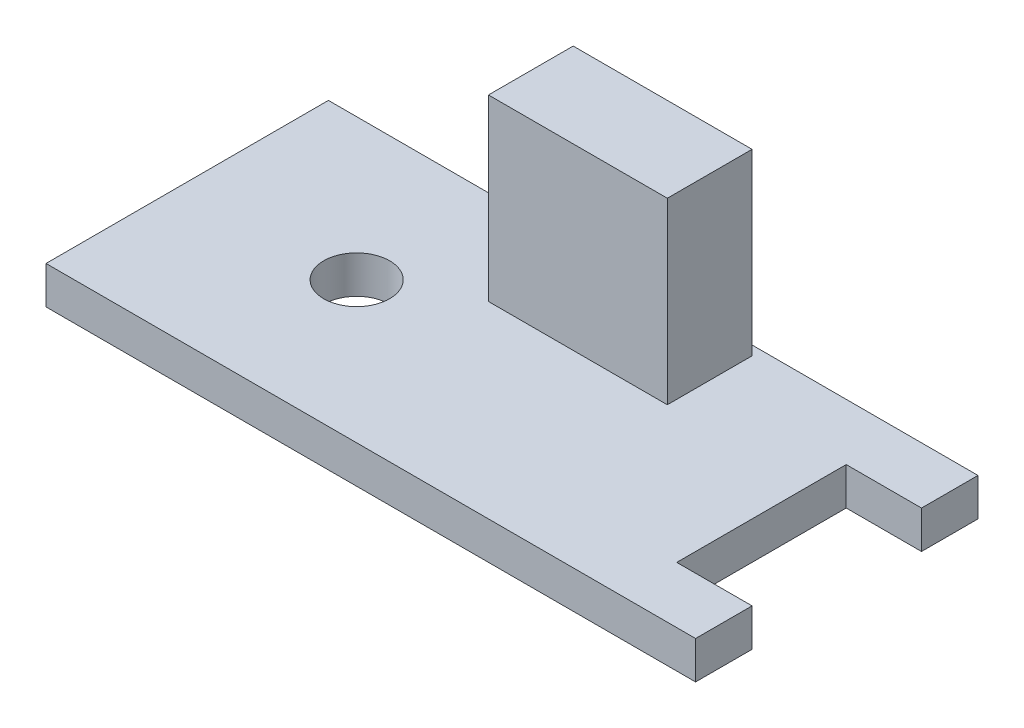
from build123d import *

# Parameters (mm, degrees)
SKETCH1_R           = 1.75
BOSS_EXTRUDE1_DEPTH = 2
SKETCH2_W           = 9.5
SKETCH2_H           = 4.5
BOSS_EXTRUDE2_DEPTH = 9.5


with BuildPart() as part:
    # Sketch1 → Boss-Extrude1 (new body)
    with BuildSketch(Plane(origin=(0, 0, 0), x_dir=(1, 0, 0), z_dir=(0, 1, 0))):
        Polygon((17.25, 4.5), (13.25, 4.5), (13.25, -4.5), (17.25, -4.5), (17.25, -7.5), (-17.25, -7.5), (-17.25, 7.5), (17.25, 7.5), align=None)
        with Locations((-8.25, 0)):
            Circle(SKETCH1_R, mode=Mode.SUBTRACT)
    extrude(amount=BOSS_EXTRUDE1_DEPTH)

    # Sketch2 → Boss-Extrude2 (add)
    with BuildSketch(Plane(origin=(0, 2, 0), x_dir=(1, 0, 0), z_dir=(0, 1, 0))):
        with Locations((1, 4.75)):
            Rectangle(SKETCH2_W, SKETCH2_H)
    extrude(amount=BOSS_EXTRUDE2_DEPTH)


solid = part.part
